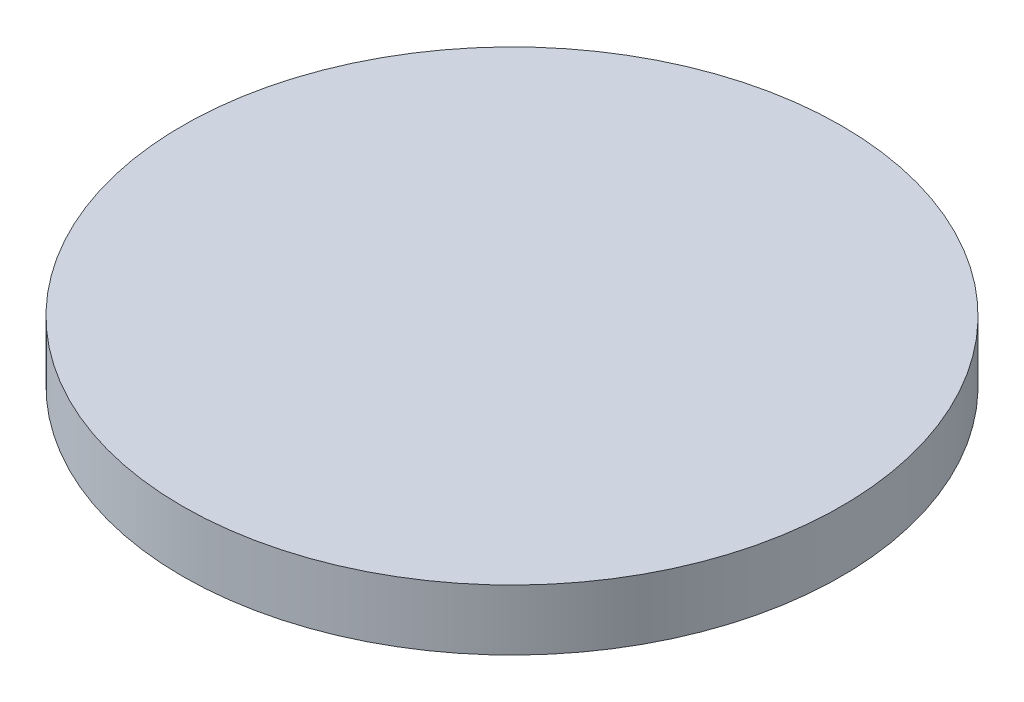
from build123d import *

# Parameters (mm, degrees)
SKETCH_1_R      = 12.5
EXTRUDE_1_DEPTH = 2.3


with BuildPart() as part:
    # 草图1 → 凸台-拉伸1 (new body)
    with BuildSketch(Plane(origin=(0, 0, 0), x_dir=(1, 0, 0), z_dir=(0, 1, 0))):
        with Locations(Location((0, 0, 0), (0, 0, 270))):  # turned: the seam where the file's is
            Circle(SKETCH_1_R)
    extrude(amount=EXTRUDE_1_DEPTH)


solid = part.part
